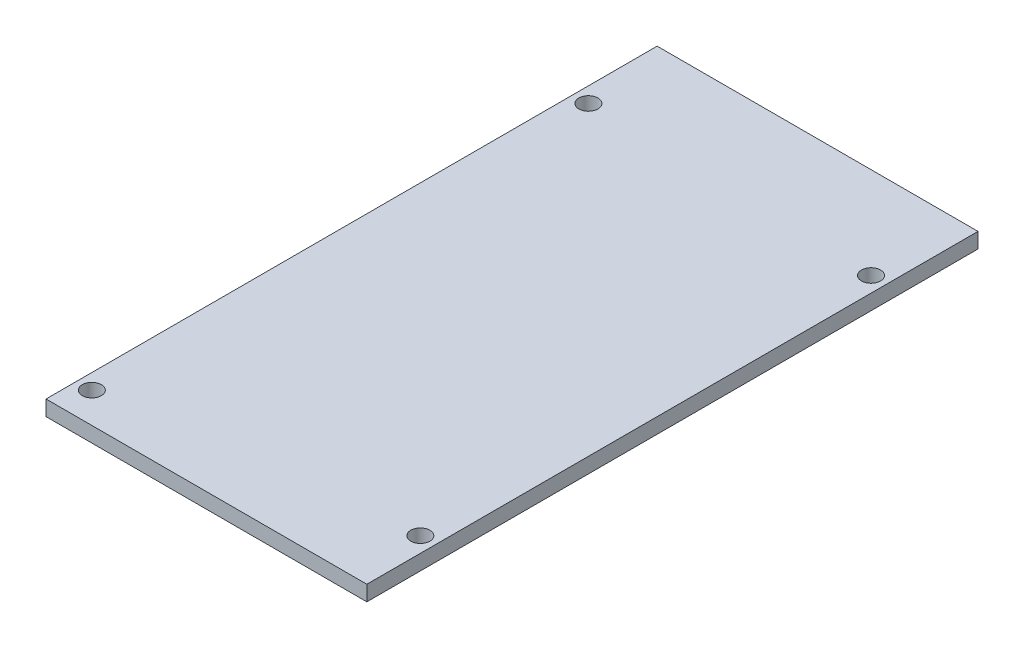
from build123d import *

# Parameters (mm, degrees)
SKETCH1_W           = 53.34
SKETCH1_H           = 101.6
SKETCH1_R           = 1.5875
BOSS_EXTRUDE1_DEPTH = 2.54


with BuildPart() as part:
    # Sketch1 → Boss-Extrude1 (new body)
    with BuildSketch(Plane(origin=(0, 0, 0), x_dir=(1, 0, 0), z_dir=(0, 1, 0))):
        with Locations((26.67, 50.8)):
            Rectangle(SKETCH1_W, SKETCH1_H)
        with Locations((50.8, 86.36)):
            Circle(SKETCH1_R, mode=Mode.SUBTRACT)
        with Locations((2.54, 87.63)):
            Circle(SKETCH1_R, mode=Mode.SUBTRACT)
        with Locations((2.54, 5.08)):
            Circle(SKETCH1_R, mode=Mode.SUBTRACT)
        with Locations((50.8, 11.43)):
            Circle(SKETCH1_R, mode=Mode.SUBTRACT)
    extrude(amount=BOSS_EXTRUDE1_DEPTH)


solid = part.part
